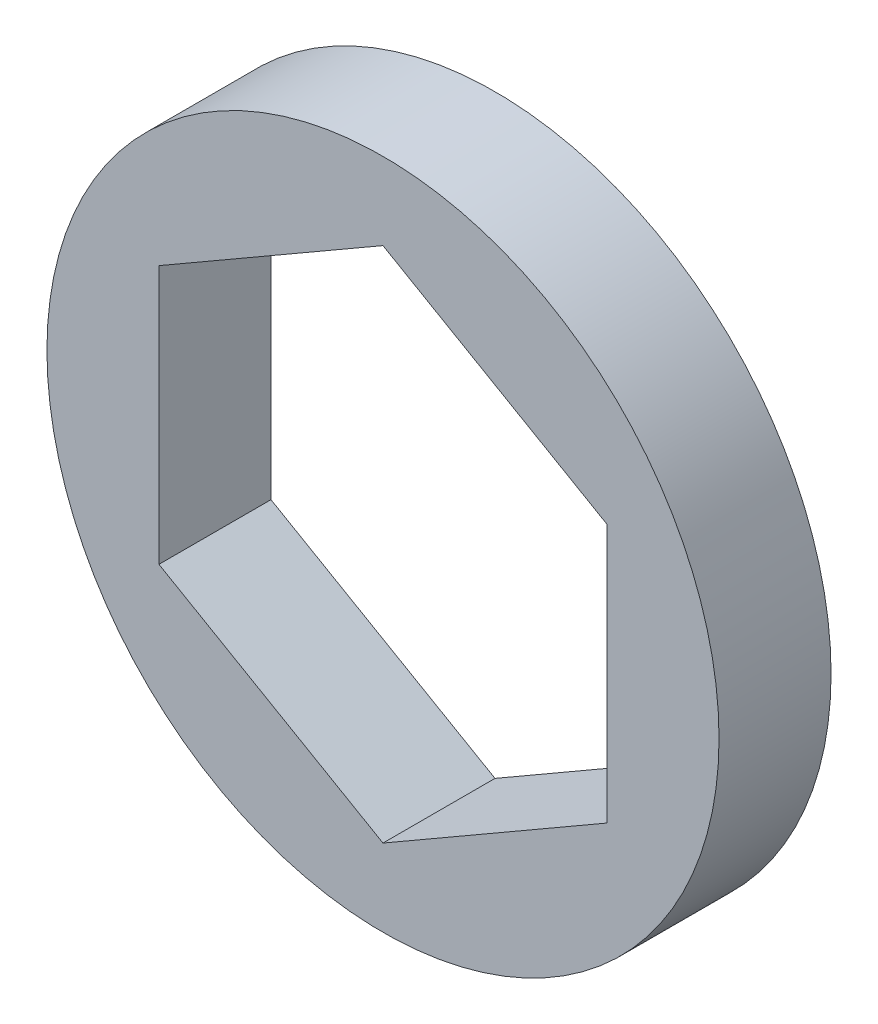
from build123d import *

# Parameters (mm, degrees)
SKETCH1_R           = 19.05
BOSS_EXTRUDE1_DEPTH = 3.175


with BuildPart() as part:
    # Sketch1 → Boss-Extrude1 (new body, symmetric)
    with BuildSketch(Plane.XY):
        Circle(SKETCH1_R)
        Polygon((0, 14.664696837), (-12.7, 7.332348419), (-12.7, -7.332348419), (0, -14.664696837), (12.7, -7.332348419), (12.7, 7.332348419), align=None, mode=Mode.SUBTRACT)
    extrude(amount=BOSS_EXTRUDE1_DEPTH, both=True)


solid = part.part
